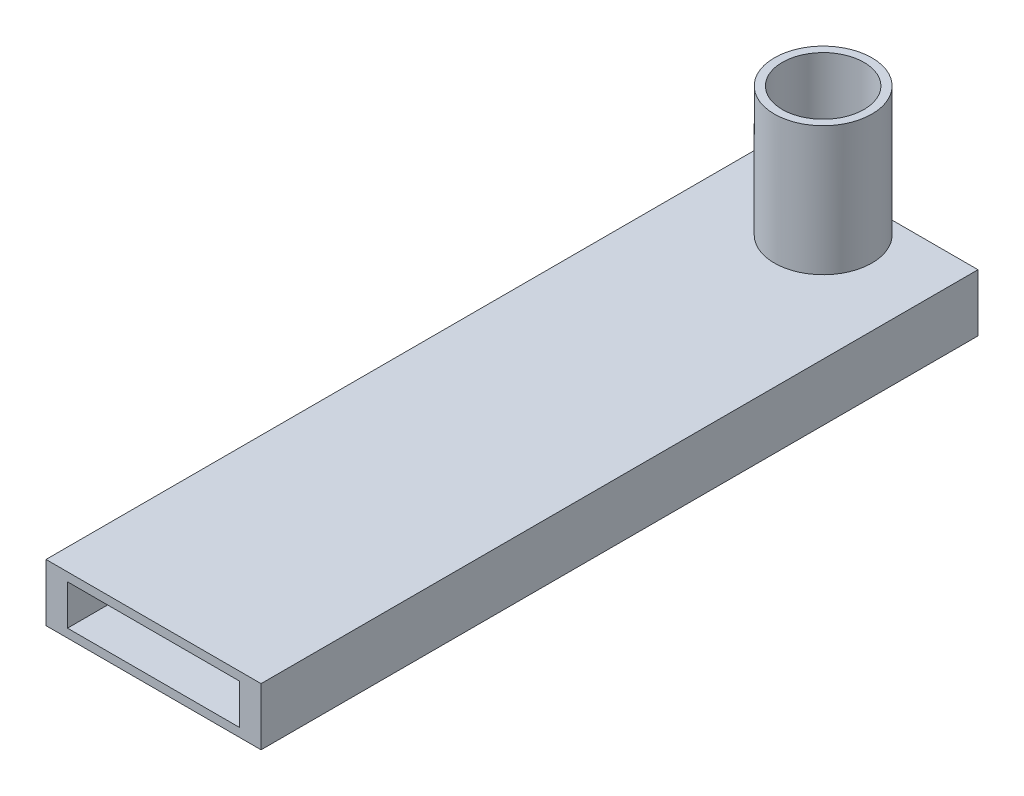
from build123d import *

# Parameters (mm, degrees)
SKETCH1_W           = 38.1
SKETCH1_H           = 10.16
BOSS_EXTRUDE1_DEPTH = 127
SKETCH2_W           = 30.48
SKETCH2_H           = 7.112
CUT_EXTRUDE1_DEPTH  = 25.4
SKETCH3_R           = 7.239
CUT_EXTRUDE2_DEPTH  = 6.35
SKETCH4_R           = 5.207
CUT_EXTRUDE3_DEPTH  = 11.16
SKETCH5_R           = 8.641264269
BOSS_EXTRUDE2_DEPTH = 22.86
SKETCH6_R           = 7.239
CUT_EXTRUDE5_DEPTH  = 22.86


with BuildPart() as part:
    # Sketch1 → Boss-Extrude1 (new body)
    with BuildSketch(Plane.XY):
        Rectangle(SKETCH1_W, SKETCH1_H)
    extrude(amount=-BOSS_EXTRUDE1_DEPTH)

    # Sketch2 → Cut-Extrude1 (cut)
    with BuildSketch(Plane.XY):
        Rectangle(SKETCH2_W, SKETCH2_H)
    extrude(amount=-CUT_EXTRUDE1_DEPTH, mode=Mode.SUBTRACT)

    # Sketch3 → Cut-Extrude2 (cut)
    with BuildSketch(Plane(origin=(0, 5.08, 0), x_dir=(1, 0, 0), z_dir=(0, 1, 0))):
        with Locations((0, 118.618)):
            Circle(SKETCH3_R)
    extrude(amount=-CUT_EXTRUDE2_DEPTH, mode=Mode.SUBTRACT)

    # Sketch4 → Cut-Extrude3 (cut, through all)
    with BuildSketch(Plane.XZ.offset(5.08)):
        with Locations((0, -118.618)):
            Circle(SKETCH4_R)
    extrude(amount=-CUT_EXTRUDE3_DEPTH, mode=Mode.SUBTRACT)

    # Sketch5 → Boss-Extrude2 (add)
    with BuildSketch(Plane(origin=(0, 5.08, 0), x_dir=(1, 0, 0), z_dir=(0, 1, 0))):
        with Locations((0, 118.618)):
            Circle(SKETCH5_R)
    extrude(amount=BOSS_EXTRUDE2_DEPTH)

    # Sketch6 → Cut-Extrude5 (cut)
    with BuildSketch(Plane(origin=(0, 27.94, 0), x_dir=(1, 0, 0), z_dir=(0, 1, 0))):
        with Locations((0, 118.618)):
            Circle(SKETCH6_R)
    extrude(amount=-CUT_EXTRUDE5_DEPTH, mode=Mode.SUBTRACT)


solid = part.part
